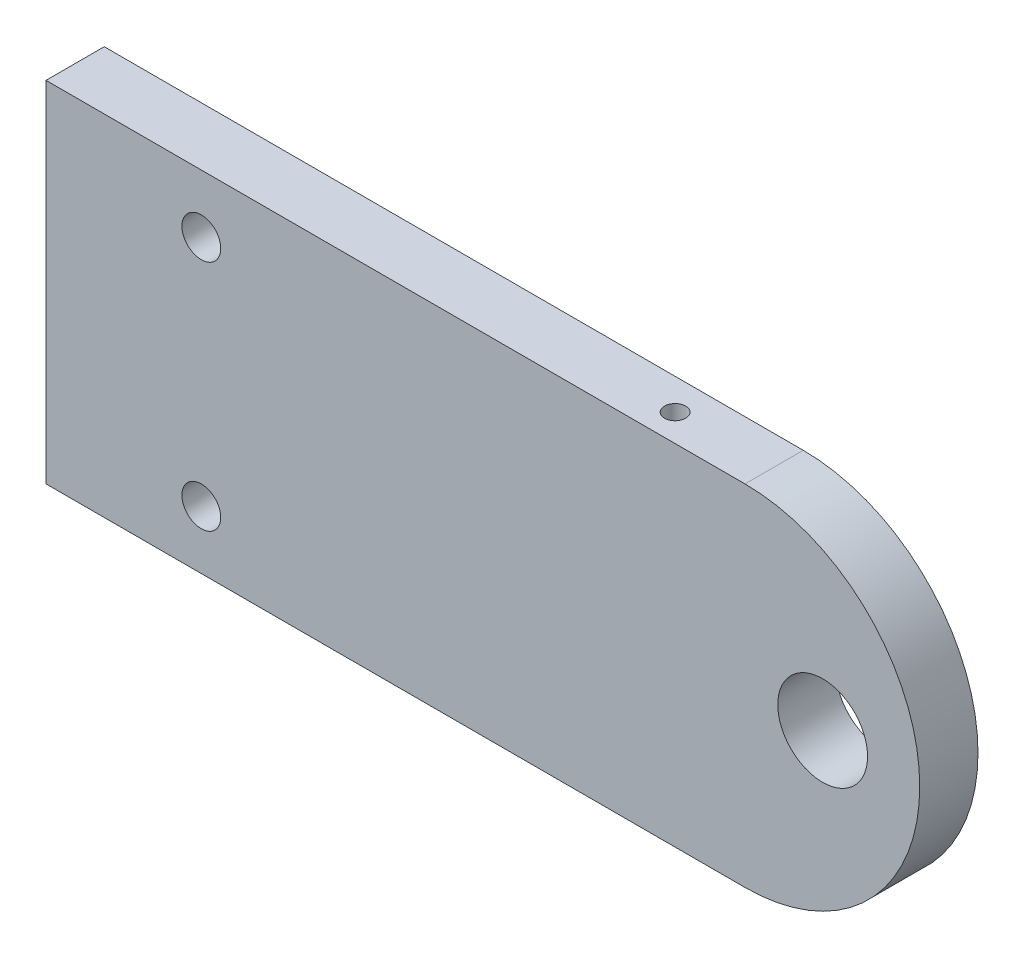
from build123d import *

# Parameters (mm, degrees)
BOSS_EXTRUDE1_DEPTH         = 9.525
F_5_8_18_TAPPED_HOLE1_D     = 14.68374
F_1_4_0_25_DIAMETER_HOLE1_D = 6.35
F_8_32_TAPPED_HOLE1_D       = 3.4544
F_8_32_TAPPED_HOLE1_DEPTH   = 12.7
F_8_32_TAPPED_HOLE1_TIP     = 1.037806461


with BuildPart() as part:
    # Sketch1 → Boss-Extrude1 (new body)
    with BuildSketch(Plane.XY):
        with BuildLine():
            Line((0, 0), (114.3, 0))
            ThreePointArc((114.3, 0), (142.875, 28.575), (114.3, 57.15))
            Line((114.3, 57.15), (0, 57.15))
            Line((0, 57.15), (0, 0))
        make_face()
    extrude(amount=BOSS_EXTRUDE1_DEPTH)

    # 5/8-18 Tapped Hole1 (through all)
    with Locations(Plane.XY.offset(9.525)):
        with Locations((127, 28.575)):
            Hole(F_5_8_18_TAPPED_HOLE1_D / 2)

    # 1/4 (0.25) Diameter Hole1 (through all)
    with Locations(Plane(origin=(25.4, 47.625, 9.525), x_dir=(1, 0, 0), z_dir=(0, 0, 1))):
        with Locations((0, 0), (0, -38.1)):
            Hole(F_1_4_0_25_DIAMETER_HOLE1_D / 2)

    # #8-32 Tapped Hole1
    with Locations(Plane(origin=(98.425, 57.15, 5.08), x_dir=(0, 0, 1), z_dir=(0, 1, 0))):
        with Locations((0, 0)):
            Hole(F_8_32_TAPPED_HOLE1_D / 2, depth=F_8_32_TAPPED_HOLE1_DEPTH)
            with Locations((0, 0, -(F_8_32_TAPPED_HOLE1_DEPTH + F_8_32_TAPPED_HOLE1_TIP / 2))):  # 118° drill point
                Cone(0, F_8_32_TAPPED_HOLE1_D / 2, F_8_32_TAPPED_HOLE1_TIP, mode=Mode.SUBTRACT)


solid = part.part
